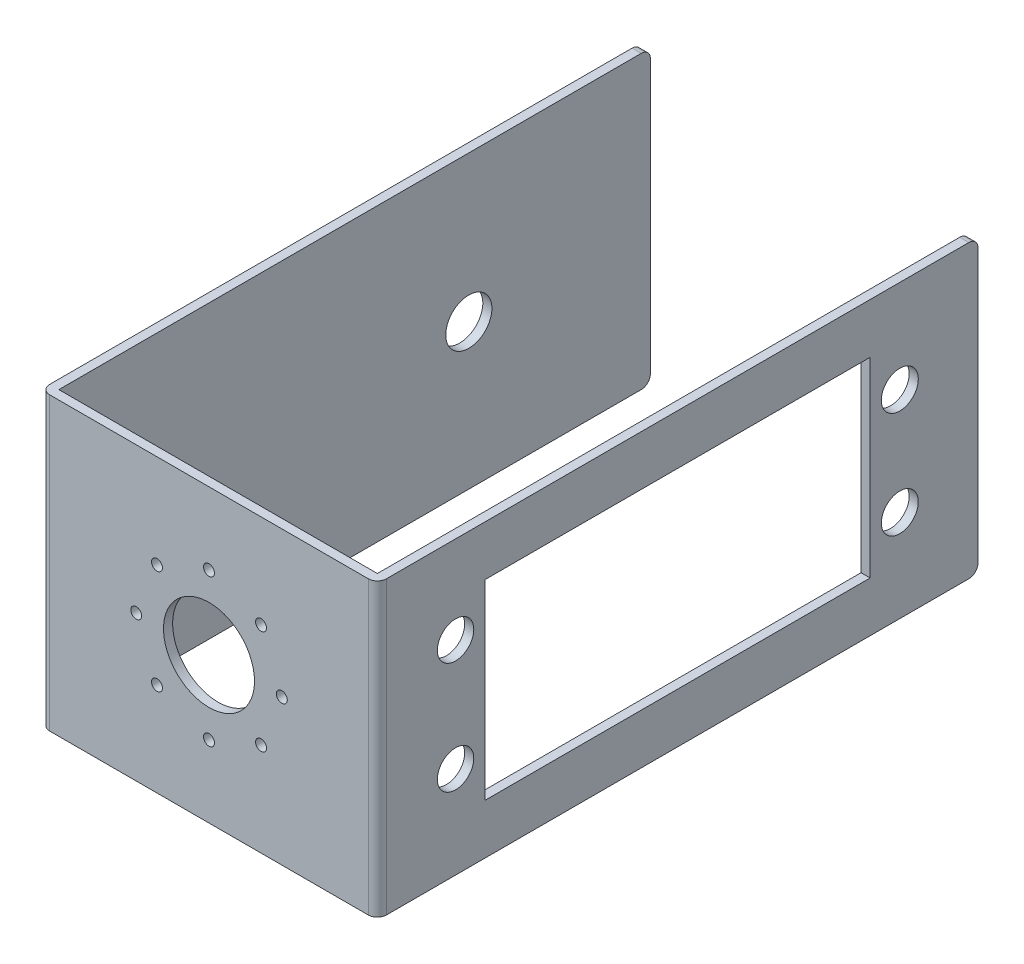
from build123d import *

# Parameters (mm, degrees)
EXTRUDE_THIN2_DEPTH = 32
FILLET4_R           = 1
FILLET5_R           = 1
FILLET6_R           = 1
FILLET7_R           = 1
FILLET8_R           = 1
FILLET9_R           = 1
SKETCH9_W           = 42.294810508
SKETCH9_H           = 21
CUT_EXTRUDE2_DEPTH  = 32
SKETCH10_R          = 5
CUT_EXTRUDE3_DEPTH  = 32
SKETCH14_R          = 0.6
CUT_EXTRUDE7_DEPTH  = 32
SKETCH15_R          = 0.6
CUT_EXTRUDE8_DEPTH  = 10
SKETCH13_R          = 2.535991587
CUT_EXTRUDE9_DEPTH  = 10
SKETCH11_R          = 2.032571361
SKETCH11_R_2        = 2.028056202
CUT_EXTRUDE12_DEPTH = 10
SKETCH16_R          = 2
CUT_EXTRUDE13_DEPTH = 10


with BuildPart() as part:
    # Sketch8 → Extrude-Thin2 (new body)
    with BuildSketch(Plane(origin=(0, 0, 0), x_dir=(1, 0, 0), z_dir=(0, 1, 0))):
        Polygon((17.5, 65), (17.5, 0), (-17.5, 0), (-17.5, 65), (-18.5, 65), (-18.5, -1), (18.5, -1), (18.5, 65), align=None)
    extrude(amount=EXTRUDE_THIN2_DEPTH)

    # Fillet4
    fillet4_edges = [part.edges().sort_by_distance(p)[0] for p in [
        (-18, 0, -65),
    ]]
    fillet(fillet4_edges, radius=FILLET4_R)

    # Fillet5
    fillet5_edges = [part.edges().sort_by_distance(p)[0] for p in [
        (-18, 32, -65),
    ]]
    fillet(fillet5_edges, radius=FILLET5_R)

    # Fillet6
    fillet6_edges = [part.edges().sort_by_distance(p)[0] for p in [
        (18, 0, -65),
    ]]
    fillet(fillet6_edges, radius=FILLET6_R)

    # Fillet7
    fillet7_edges = [part.edges().sort_by_distance(p)[0] for p in [
        (18, 32, -65),
    ]]
    fillet(fillet7_edges, radius=FILLET7_R)

    # Fillet8
    fillet8_edges = [part.edges().sort_by_distance(p)[0] for p in [
        (18.5, 16, 1),
    ]]
    fillet(fillet8_edges, radius=FILLET8_R)

    # Fillet9
    fillet9_edges = [part.edges().sort_by_distance(p)[0] for p in [
        (-18.5, 16, 1),
    ]]
    fillet(fillet9_edges, radius=FILLET9_R)

    # Sketch9 → Cut-Extrude2 (cut)
    with BuildSketch(Plane(origin=(18.5, 0, 0), x_dir=(0, 0, -1), z_dir=(1, 0, 0))):
        with Locations((32, 16)):
            Rectangle(SKETCH9_W, SKETCH9_H)
    extrude(amount=-CUT_EXTRUDE2_DEPTH, mode=Mode.SUBTRACT)

    # Sketch10 → Cut-Extrude3 (cut)
    with BuildSketch(Plane.XY.offset(1)):
        with Locations((0, 16)):
            Circle(SKETCH10_R)
    extrude(amount=-CUT_EXTRUDE3_DEPTH, mode=Mode.SUBTRACT)

    # Sketch14 → Cut-Extrude7 (cut)
    with BuildSketch(Plane.XY.offset(1)):
        with Locations((0, 7.914892415)):
            Circle(SKETCH14_R)
        with Locations((0, 24.085107585)):
            Circle(SKETCH14_R)
        with Locations((-5.7170344, 10.2829656)):
            Circle(SKETCH14_R)
        with Locations((-5.7170344, 21.7170344)):
            Circle(SKETCH14_R)
        with Locations((5.7170344, 10.2829656)):
            Circle(SKETCH14_R)
        with Locations((5.7170344, 21.7170344)):
            Circle(SKETCH14_R)
    extrude(amount=-CUT_EXTRUDE7_DEPTH, mode=Mode.SUBTRACT)

    # Sketch15 → Cut-Extrude8 (cut)
    with BuildSketch(Plane.XY.offset(1)):
        with Locations((-8, 16)):
            Circle(SKETCH15_R)
        with Locations((8, 16)):
            Circle(SKETCH15_R)
    extrude(amount=-CUT_EXTRUDE8_DEPTH, mode=Mode.SUBTRACT)

    # Sketch13 → Cut-Extrude9 (cut)
    with BuildSketch(Plane.ZY.offset(18.5)):
        with Locations((-45.049639152, 15.939767339)):
            Circle(SKETCH13_R)
    extrude(amount=-CUT_EXTRUDE9_DEPTH, mode=Mode.SUBTRACT)

    # Sketch11 → Cut-Extrude12 (cut)
    with BuildSketch(Plane(origin=(18.5, 0, 0), x_dir=(0, 0, -1), z_dir=(1, 0, 0))):
        with Locations((56.406137915, 21.793575716)):
            Circle(SKETCH11_R)
        with Locations((56.406137915, 10.115569331)):
            Circle(SKETCH11_R_2)
    extrude(amount=-CUT_EXTRUDE12_DEPTH, mode=Mode.SUBTRACT)

    # Sketch16 → Cut-Extrude13 (cut)
    with BuildSketch(Plane(origin=(18.5, 0, 0), x_dir=(0, 0, -1), z_dir=(1, 0, 0))):
        with Locations((7.592594746, 22.385297204)):
            Circle(SKETCH16_R)
        with Locations((7.592594746, 10.115569331)):
            Circle(SKETCH16_R)
    extrude(amount=-CUT_EXTRUDE13_DEPTH, mode=Mode.SUBTRACT)


solid = part.part
